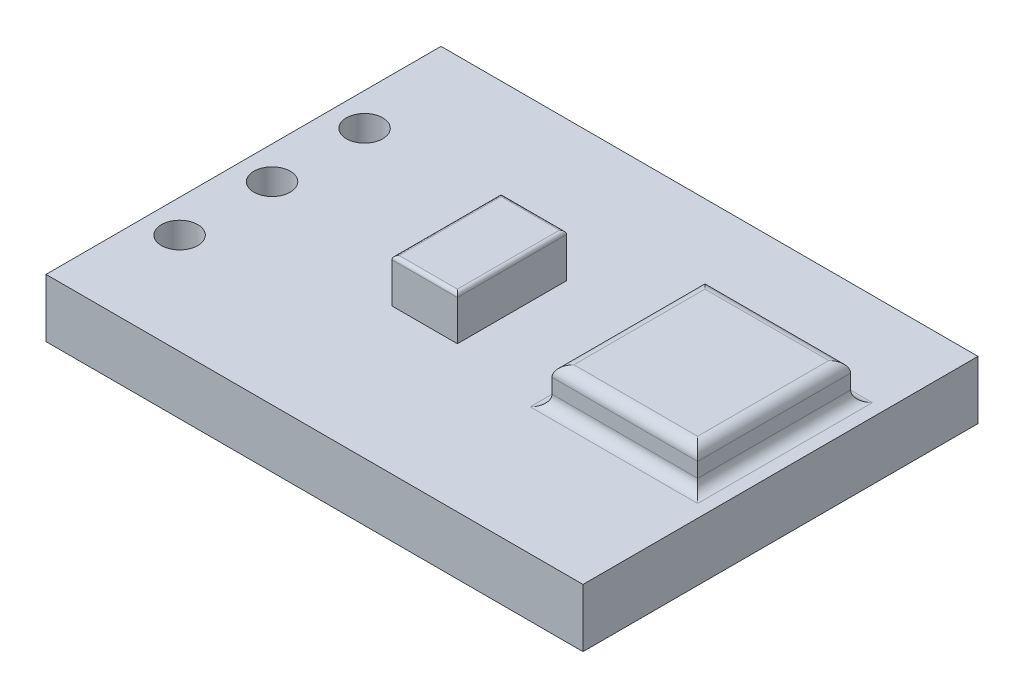
from build123d import *

# Parameters (mm, degrees)
SKETCH1_W        = 14.75
SKETCH1_H        = 10.85
MIC_BOARD_DEPTH  = 1.6
SKETCH2_R        = 0.5
PINS_DEPTH       = 1.6
MIC_SKETCH_W     = 4
MIC_SKETCH_H     = 4.2
MICROPHONE_DEPTH = 1
OP_AMP_SKETCH_W  = 1.8
OP_AMP_SKETCH_H  = 3
OP_AMP_DEPTH     = 1.2
MIC_FILLET_R     = 0.3
OP_AMP_FILLET_R  = 0.1


with BuildPart() as part:
    # Sketch1 → Mic Board (new body)
    with BuildSketch(Plane(origin=(0, 0, 0), x_dir=(1, 0, 0), z_dir=(0, 1, 0))):
        with Locations((-347.05792854, -6.593292201)):
            Rectangle(SKETCH1_W, SKETCH1_H)
    extrude(amount=MIC_BOARD_DEPTH)

    # Sketch2 → Pins (cut)
    with BuildSketch(Plane(origin=(0, 1.6, 0), x_dir=(1, 0, 0), z_dir=(0, 1, 0))):
        with Locations((-353.53292854, -4.168292201)):
            Circle(SKETCH2_R)
        with Locations((-353.53292854, -6.708292201)):
            Circle(SKETCH2_R)
        with Locations((-353.53292854, -9.248292201)):
            Circle(SKETCH2_R)
    extrude(amount=-PINS_DEPTH, mode=Mode.SUBTRACT)

    # mic Sketch → Microphone (add)
    with BuildSketch(Plane(origin=(0, 1.6, 0), x_dir=(1, 0, 0), z_dir=(0, 1, 0))):
        with Locations((-342.33292854, -6.118292201)):
            Rectangle(MIC_SKETCH_W, MIC_SKETCH_H)
    extrude(amount=MICROPHONE_DEPTH)

    # Op Amp Sketch → Op Amp (add)
    with BuildSketch(Plane(origin=(0, 1.6, 0), x_dir=(1, 0, 0), z_dir=(0, 1, 0))):
        with Locations((-348.03292854, -6.518292201)):
            Rectangle(OP_AMP_SKETCH_W, OP_AMP_SKETCH_H)
    extrude(amount=OP_AMP_DEPTH)

    # Mic Fillet
    mic_fillet_edges = [part.edges().sort_by_distance(p)[0] for p in [
        (-342.33292854, 2.6, 4.018292201),
        (-344.33292854, 1.6, 6.118292201),
        (-342.33292854, 1.6, 8.218292201),
        (-340.33292854, 2.6, 6.118292201),
        (-344.33292854, 2.6, 6.118292201),
        (-342.33292854, 2.6, 8.218292201),
        (-342.33292854, 1.6, 4.018292201),
        (-340.33292854, 1.6, 6.118292201),
    ]]
    fillet(mic_fillet_edges, radius=MIC_FILLET_R)

    # Op Amp Fillet
    op_amp_fillet_edges = [part.edges().sort_by_distance(p)[0] for p in [
        (-348.93292854, 2.8, 6.518292201),
        (-348.03292854, 2.8, 8.018292201),
        (-347.13292854, 2.8, 6.518292201),
        (-348.03292854, 2.8, 5.018292201),
    ]]
    fillet(op_amp_fillet_edges, radius=OP_AMP_FILLET_R)


solid = part.part
